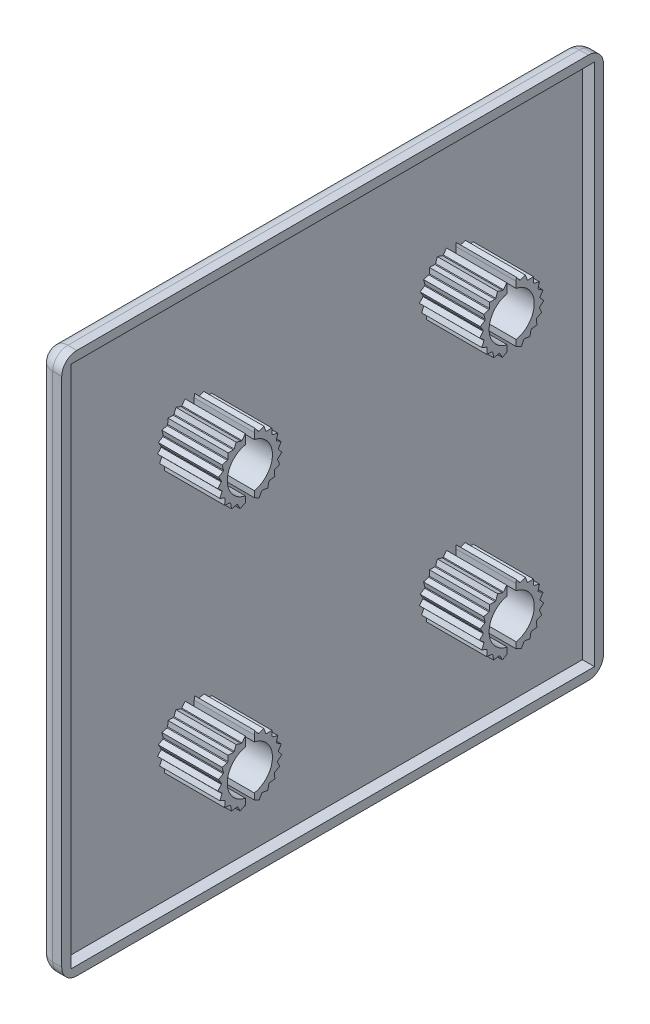
from build123d import *

# Parameters (mm, degrees)
EXTRUDE_3_DEPTH      = 45
EXTRUDE_3_DEPTH_BACK = 45
FILLET_3_R           = 2.5
SKETCH_6_W           = 87
SKETCH_6_H           = 87
CUT_EXTRUDE_2_DEPTH  = 2
EXTRUDE_5_DEPTH      = 10


with BuildPart() as part:
    # Sketch 3 → Extrude 3 (new body, two sides)
    with BuildSketch(Plane.XY) as extrude_3_sk:
        with BuildLine():
            Line((0.5, -45), (2, -45))
            Line((2, -45), (2, 45))
            Line((2, 45), (0.5, 45))
            ThreePointArc((0.5, 45), (-1.267766953, 44.267766953), (-2, 42.5))
            Line((-2, 42.5), (-2, -42.5))
            ThreePointArc((-2, -42.5), (-1.267766953, -44.267766953), (0.5, -45))
        make_face()
    extrude(amount=EXTRUDE_3_DEPTH)
    extrude(extrude_3_sk.sketch, amount=-EXTRUDE_3_DEPTH_BACK)

    # Fillet 3
    fillet_3_edges = [part.edges().sort_by_distance(p)[0] for p in [
        (-1.267766953, 44.267766953, -45),
        (-2, 0, -45),
        (1.25, 45, 45),
        (-1.267766953, 44.267766953, 45),
        (-2, 0, 45),
        (-1.267766953, -44.267766953, 45),
        (1.25, -45, 45),
        (-1.267766953, -44.267766953, -45),
        (1.25, -45, -45),
        (1.25, 45, -45),
    ]]
    fillet(fillet_3_edges, radius=FILLET_3_R)

    # Sketch 6 → Cut-Extrude 2 (cut)
    with BuildSketch(Plane(origin=(2, 0, 0), x_dir=(0, 0, -1), z_dir=(1, 0, 0))):
        Rectangle(SKETCH_6_W, SKETCH_6_H)
    extrude(amount=-CUT_EXTRUDE_2_DEPTH, mode=Mode.SUBTRACT)

    # Sketch 7 → Extrude 5 (add)
    with BuildSketch(Plane(origin=(0, 0, 0), x_dir=(0, 0, -1), z_dir=(1, 0, 0))):
        with BuildLine():
            Line((22.5, 17.05958424), (22.5, 18.075765386))
            ThreePointArc((22.5, 18.075765386), (25.5, 21.75), (22.5, 25.424234614))
            Line((22.5, 25.424234614), (22.5, 26.44041576))
            Line((22.5, 26.44041576), (22.513331825, 27.038769295))
            Line((22.513331825, 27.038769295), (23.052291729, 26.317990395))
            ThreePointArc((23.052291729, 26.317990395), (23.121651335, 26.297644733), (23.190693314, 26.276245991))
            Line((23.190693314, 26.276245991), (24.03831125, 26.578808109))
            Line((24.03831125, 26.578808109), (24.340873367, 25.731190173))
            ThreePointArc((24.340873367, 25.731190173), (24.401154531, 25.691304308), (24.460821779, 25.650505773))
            Line((24.460821779, 25.650505773), (25.359964178, 25.689786132))
            Line((25.359964178, 25.689786132), (25.399244537, 24.790643733))
            ThreePointArc((25.399244537, 24.790643733), (25.445091013, 24.7347617), (25.490081833, 24.678188499))
            Line((25.490081833, 24.678188499), (26.360855946, 24.450696867))
            Line((26.360855946, 24.450696867), (26.133364315, 23.579922753))
            ThreePointArc((26.133364315, 23.579922753), (26.160702442, 23.513009917), (26.187019202, 23.445688827))
            Line((26.187019202, 23.445688827), (26.95205293, 22.971638834))
            Line((26.95205293, 22.971638834), (26.478002937, 22.206605107))
            ThreePointArc((26.478002937, 22.206605107), (26.484403604, 22.134606965), (26.489707944, 22.062519761))
            Line((26.489707944, 22.062519761), (27.081024682, 21.38403283))
            Line((27.081024682, 21.38403283), (26.402537751, 20.792716093))
            ThreePointArc((26.402537751, 20.792716093), (26.387432228, 20.722029997), (26.371252836, 20.651581943))
            Line((26.371252836, 20.651581943), (26.736311496, 19.828944615))
            Line((26.736311496, 19.828944615), (25.913674167, 19.463885955))
            ThreePointArc((25.913674167, 19.463885955), (25.878404648, 19.400792674), (25.842179133, 19.33824339))
            Line((25.842179133, 19.33824339), (25.948542652, 18.444550601))
            Line((25.948542652, 18.444550601), (25.054849862, 18.338187082))
            ThreePointArc((25.054849862, 18.338187082), (25.002550198, 18.288292732), (24.949497356, 18.239199995))
            Line((24.949497356, 18.239199995), (24.787714868, 17.353860272))
            Line((24.787714868, 17.353860272), (23.902375144, 17.515642759))
            ThreePointArc((23.902375144, 17.515642759), (23.83769239, 17.483380672), (23.772526197, 17.452106588))
            Line((23.772526197, 17.452106588), (23.356972787, 16.653786249))
            Line((23.356972787, 16.653786249), (22.558652448, 17.06933966))
            ThreePointArc((22.558652448, 17.06933966), (22.529341488, 17.064370176), (22.5, 17.05958424))
        make_face()
        with BuildLine():
            Line((21, 17.05958424), (21, 18.075765386))
            ThreePointArc((21, 18.075765386), (18, 21.75), (21, 25.424234614))
            Line((21, 25.424234614), (21, 26.44041576))
            Line((21, 26.44041576), (20.920527018, 27.028800119))
            Line((20.920527018, 27.028800119), (20.390631523, 26.301331381))
            ThreePointArc((20.390631523, 26.301331381), (20.321532023, 26.28011912), (20.252763307, 26.257857838))
            Line((20.252763307, 26.257857838), (19.401424525, 26.549786388))
            Line((19.401424525, 26.549786388), (19.109495975, 25.698447606))
            ThreePointArc((19.109495975, 25.698447606), (19.049718796, 25.65781031), (18.990566909, 25.6162681))
            Line((18.990566909, 25.6162681), (18.09100327, 25.644290572))
            Line((18.09100327, 25.644290572), (18.062980798, 24.744726933))
            ThreePointArc((18.062980798, 24.744726933), (18.017837404, 24.688275405), (17.973558251, 24.631143474))
            Line((17.973558251, 24.631143474), (17.105699932, 24.392769949))
            Line((17.105699932, 24.392769949), (17.344073456, 23.52491163))
            ThreePointArc((17.344073456, 23.52491163), (17.317575037, 23.457661836), (17.292103015, 23.390016607))
            Line((17.292103015, 23.390016607), (16.533063036, 22.906427619))
            Line((16.533063036, 22.906427619), (17.016652024, 22.147387639))
            ThreePointArc((17.016652024, 22.147387639), (17.011153079, 22.075315019), (17.006751489, 22.003167067))
            Line((17.006751489, 22.003167067), (16.423973883, 21.317331619))
            Line((16.423973883, 21.317331619), (17.109809331, 20.734554013))
            ThreePointArc((17.109809331, 20.734554013), (17.125798467, 20.664062535), (17.142858409, 20.593822523))
            Line((17.142858409, 20.593822523), (16.788125523, 19.766680104))
            Line((16.788125523, 19.766680104), (17.615267942, 19.411947219))
            ThreePointArc((17.615267942, 19.411947219), (17.651324453, 19.34930036), (17.688330077, 19.287209421))
            Line((17.688330077, 19.287209421), (17.593161486, 18.392255266))
            Line((17.593161486, 18.392255266), (18.488115641, 18.297086675))
            ThreePointArc((18.488115641, 18.297086675), (18.541035749, 18.247850884), (18.594698942, 18.19942607))
            Line((18.594698942, 18.19942607), (18.767550793, 17.316180782))
            Line((18.767550793, 17.316180782), (19.65079608, 17.489032633))
            ThreePointArc((19.65079608, 17.489032633), (19.7158776, 17.457582725), (19.781430153, 17.427126794))
            Line((19.781430153, 17.427126794), (20.2069438, 16.634070594))
            Line((20.2069438, 16.634070594), (21, 17.05958424))
        make_face()
        with BuildLine():
            Line((-22.5, 26.44041576), (-22.513331825, 27.038769295))
            Line((-22.513331825, 27.038769295), (-23.052291729, 26.317990395))
            ThreePointArc((-23.052291729, 26.317990395), (-23.121651335, 26.297644733), (-23.190693314, 26.276245991))
            Line((-23.190693314, 26.276245991), (-24.03831125, 26.578808109))
            Line((-24.03831125, 26.578808109), (-24.340873367, 25.731190173))
            ThreePointArc((-24.340873367, 25.731190173), (-24.401154531, 25.691304308), (-24.460821779, 25.650505773))
            Line((-24.460821779, 25.650505773), (-25.359964178, 25.689786132))
            Line((-25.359964178, 25.689786132), (-25.399244537, 24.790643733))
            ThreePointArc((-25.399244537, 24.790643733), (-25.445091013, 24.7347617), (-25.490081833, 24.678188499))
            Line((-25.490081833, 24.678188499), (-26.360855946, 24.450696867))
            Line((-26.360855946, 24.450696867), (-26.133364315, 23.579922753))
            ThreePointArc((-26.133364315, 23.579922753), (-26.160702442, 23.513009917), (-26.187019202, 23.445688827))
            Line((-26.187019202, 23.445688827), (-26.95205293, 22.971638834))
            Line((-26.95205293, 22.971638834), (-26.478002937, 22.206605107))
            ThreePointArc((-26.478002937, 22.206605107), (-26.484403604, 22.134606965), (-26.489707944, 22.062519761))
            Line((-26.489707944, 22.062519761), (-27.081024682, 21.38403283))
            Line((-27.081024682, 21.38403283), (-26.402537751, 20.792716093))
            ThreePointArc((-26.402537751, 20.792716093), (-26.387432228, 20.722029997), (-26.371252836, 20.651581943))
            Line((-26.371252836, 20.651581943), (-26.736311496, 19.828944615))
            Line((-26.736311496, 19.828944615), (-25.913674167, 19.463885955))
            ThreePointArc((-25.913674167, 19.463885955), (-25.878404648, 19.400792674), (-25.842179133, 19.33824339))
            Line((-25.842179133, 19.33824339), (-25.948542652, 18.444550601))
            Line((-25.948542652, 18.444550601), (-25.054849862, 18.338187082))
            ThreePointArc((-25.054849862, 18.338187082), (-25.002550198, 18.288292732), (-24.949497356, 18.239199995))
            Line((-24.949497356, 18.239199995), (-24.787714868, 17.353860272))
            Line((-24.787714868, 17.353860272), (-23.902375144, 17.515642759))
            ThreePointArc((-23.902375144, 17.515642759), (-23.83769239, 17.483380672), (-23.772526197, 17.452106588))
            Line((-23.772526197, 17.452106588), (-23.356972787, 16.653786249))
            Line((-23.356972787, 16.653786249), (-22.558652448, 17.06933966))
            ThreePointArc((-22.558652448, 17.06933966), (-22.529341488, 17.064370176), (-22.5, 17.05958424))
            Line((-22.5, 17.05958424), (-22.5, 18.075765386))
            ThreePointArc((-22.5, 18.075765386), (-25.5, 21.75), (-22.5, 25.424234614))
            Line((-22.5, 25.424234614), (-22.5, 26.44041576))
        make_face()
        with BuildLine():
            Line((-21, 26.44041576), (-20.920527018, 27.028800119))
            Line((-20.920527018, 27.028800119), (-20.390631523, 26.301331381))
            ThreePointArc((-20.390631523, 26.301331381), (-20.321532023, 26.28011912), (-20.252763307, 26.257857838))
            Line((-20.252763307, 26.257857838), (-19.401424525, 26.549786388))
            Line((-19.401424525, 26.549786388), (-19.109495975, 25.698447606))
            ThreePointArc((-19.109495975, 25.698447606), (-19.049718796, 25.65781031), (-18.990566909, 25.6162681))
            Line((-18.990566909, 25.6162681), (-18.09100327, 25.644290572))
            Line((-18.09100327, 25.644290572), (-18.062980798, 24.744726933))
            ThreePointArc((-18.062980798, 24.744726933), (-18.017837404, 24.688275405), (-17.973558251, 24.631143474))
            Line((-17.973558251, 24.631143474), (-17.105699932, 24.392769949))
            Line((-17.105699932, 24.392769949), (-17.344073456, 23.52491163))
            ThreePointArc((-17.344073456, 23.52491163), (-17.317575037, 23.457661836), (-17.292103015, 23.390016607))
            Line((-17.292103015, 23.390016607), (-16.533063036, 22.906427619))
            Line((-16.533063036, 22.906427619), (-17.016652024, 22.147387639))
            ThreePointArc((-17.016652024, 22.147387639), (-17.011153079, 22.075315019), (-17.006751489, 22.003167067))
            Line((-17.006751489, 22.003167067), (-16.423973883, 21.317331619))
            Line((-16.423973883, 21.317331619), (-17.109809331, 20.734554013))
            ThreePointArc((-17.109809331, 20.734554013), (-17.125798467, 20.664062535), (-17.142858409, 20.593822523))
            Line((-17.142858409, 20.593822523), (-16.788125523, 19.766680104))
            Line((-16.788125523, 19.766680104), (-17.615267942, 19.411947219))
            ThreePointArc((-17.615267942, 19.411947219), (-17.651324453, 19.34930036), (-17.688330077, 19.287209421))
            Line((-17.688330077, 19.287209421), (-17.593161486, 18.392255266))
            Line((-17.593161486, 18.392255266), (-18.488115641, 18.297086675))
            ThreePointArc((-18.488115641, 18.297086675), (-18.541035749, 18.247850884), (-18.594698942, 18.19942607))
            Line((-18.594698942, 18.19942607), (-18.767550793, 17.316180782))
            Line((-18.767550793, 17.316180782), (-19.65079608, 17.489032633))
            ThreePointArc((-19.65079608, 17.489032633), (-19.7158776, 17.457582725), (-19.781430153, 17.427126794))
            Line((-19.781430153, 17.427126794), (-20.2069438, 16.634070594))
            Line((-20.2069438, 16.634070594), (-21, 17.05958424))
            Line((-21, 17.05958424), (-21, 18.075765386))
            ThreePointArc((-21, 18.075765386), (-18, 21.75), (-21, 25.424234614))
            Line((-21, 25.424234614), (-21, 26.44041576))
        make_face()
        with BuildLine():
            Line((22.5, -26.44041576), (22.5, -25.424234614))
            ThreePointArc((22.5, -25.424234614), (25.5, -21.75), (22.5, -18.075765386))
            Line((22.5, -18.075765386), (22.5, -17.05958424))
            Line((22.5, -17.05958424), (22.513331825, -16.461230705))
            Line((22.513331825, -16.461230705), (23.052291729, -17.182009605))
            ThreePointArc((23.052291729, -17.182009605), (23.121651335, -17.202355267), (23.190693314, -17.223754009))
            Line((23.190693314, -17.223754009), (24.03831125, -16.921191891))
            Line((24.03831125, -16.921191891), (24.340873367, -17.768809827))
            ThreePointArc((24.340873367, -17.768809827), (24.401154531, -17.808695692), (24.460821779, -17.849494227))
            Line((24.460821779, -17.849494227), (25.359964178, -17.810213868))
            Line((25.359964178, -17.810213868), (25.399244537, -18.709356267))
            ThreePointArc((25.399244537, -18.709356267), (25.445091013, -18.7652383), (25.490081833, -18.821811501))
            Line((25.490081833, -18.821811501), (26.360855946, -19.049303133))
            Line((26.360855946, -19.049303133), (26.133364315, -19.920077247))
            ThreePointArc((26.133364315, -19.920077247), (26.160702442, -19.986990083), (26.187019202, -20.054311173))
            Line((26.187019202, -20.054311173), (26.95205293, -20.528361166))
            Line((26.95205293, -20.528361166), (26.478002937, -21.293394893))
            ThreePointArc((26.478002937, -21.293394893), (26.484403604, -21.365393035), (26.489707944, -21.437480239))
            Line((26.489707944, -21.437480239), (27.081024682, -22.11596717))
            Line((27.081024682, -22.11596717), (26.402537751, -22.707283907))
            ThreePointArc((26.402537751, -22.707283907), (26.387432228, -22.777970003), (26.371252836, -22.848418057))
            Line((26.371252836, -22.848418057), (26.736311496, -23.671055385))
            Line((26.736311496, -23.671055385), (25.913674167, -24.036114045))
            ThreePointArc((25.913674167, -24.036114045), (25.878404648, -24.099207326), (25.842179133, -24.16175661))
            Line((25.842179133, -24.16175661), (25.948542652, -25.055449399))
            Line((25.948542652, -25.055449399), (25.054849862, -25.161812918))
            ThreePointArc((25.054849862, -25.161812918), (25.002550198, -25.211707268), (24.949497356, -25.260800005))
            Line((24.949497356, -25.260800005), (24.787714868, -26.146139728))
            Line((24.787714868, -26.146139728), (23.902375144, -25.984357241))
            ThreePointArc((23.902375144, -25.984357241), (23.83769239, -26.016619328), (23.772526197, -26.047893412))
            Line((23.772526197, -26.047893412), (23.356972787, -26.846213751))
            Line((23.356972787, -26.846213751), (22.558652448, -26.43066034))
            ThreePointArc((22.558652448, -26.43066034), (22.529341488, -26.435629824), (22.5, -26.44041576))
        make_face()
        with BuildLine():
            Line((21, -26.44041576), (21, -25.424234614))
            ThreePointArc((21, -25.424234614), (18, -21.75), (21, -18.075765386))
            Line((21, -18.075765386), (21, -17.05958424))
            Line((21, -17.05958424), (20.920527018, -16.471199881))
            Line((20.920527018, -16.471199881), (20.390631523, -17.198668619))
            ThreePointArc((20.390631523, -17.198668619), (20.321532023, -17.21988088), (20.252763307, -17.242142162))
            Line((20.252763307, -17.242142162), (19.401424525, -16.950213612))
            Line((19.401424525, -16.950213612), (19.109495975, -17.801552394))
            ThreePointArc((19.109495975, -17.801552394), (19.049718796, -17.84218969), (18.990566909, -17.8837319))
            Line((18.990566909, -17.8837319), (18.09100327, -17.855709428))
            Line((18.09100327, -17.855709428), (18.062980798, -18.755273067))
            ThreePointArc((18.062980798, -18.755273067), (18.017837404, -18.811724595), (17.973558251, -18.868856526))
            Line((17.973558251, -18.868856526), (17.105699932, -19.107230051))
            Line((17.105699932, -19.107230051), (17.344073456, -19.97508837))
            ThreePointArc((17.344073456, -19.97508837), (17.317575037, -20.042338164), (17.292103015, -20.109983393))
            Line((17.292103015, -20.109983393), (16.533063036, -20.593572381))
            Line((16.533063036, -20.593572381), (17.016652024, -21.352612361))
            ThreePointArc((17.016652024, -21.352612361), (17.011153079, -21.424684981), (17.006751489, -21.496832933))
            Line((17.006751489, -21.496832933), (16.423973883, -22.182668381))
            Line((16.423973883, -22.182668381), (17.109809331, -22.765445987))
            ThreePointArc((17.109809331, -22.765445987), (17.125798467, -22.835937465), (17.142858409, -22.906177477))
            Line((17.142858409, -22.906177477), (16.788125523, -23.733319896))
            Line((16.788125523, -23.733319896), (17.615267942, -24.088052781))
            ThreePointArc((17.615267942, -24.088052781), (17.651324453, -24.15069964), (17.688330077, -24.212790579))
            Line((17.688330077, -24.212790579), (17.593161486, -25.107744734))
            Line((17.593161486, -25.107744734), (18.488115641, -25.202913325))
            ThreePointArc((18.488115641, -25.202913325), (18.541035749, -25.252149116), (18.594698942, -25.30057393))
            Line((18.594698942, -25.30057393), (18.767550793, -26.183819218))
            Line((18.767550793, -26.183819218), (19.65079608, -26.010967367))
            ThreePointArc((19.65079608, -26.010967367), (19.7158776, -26.042417275), (19.781430153, -26.072873206))
            Line((19.781430153, -26.072873206), (20.2069438, -26.865929406))
            Line((20.2069438, -26.865929406), (21, -26.44041576))
        make_face()
        with BuildLine():
            Line((-22.5, -17.05958424), (-22.513331825, -16.461230705))
            Line((-22.513331825, -16.461230705), (-23.052291729, -17.182009605))
            ThreePointArc((-23.052291729, -17.182009605), (-23.121651335, -17.202355267), (-23.190693314, -17.223754009))
            Line((-23.190693314, -17.223754009), (-24.03831125, -16.921191891))
            Line((-24.03831125, -16.921191891), (-24.340873367, -17.768809827))
            ThreePointArc((-24.340873367, -17.768809827), (-24.401154531, -17.808695692), (-24.460821779, -17.849494227))
            Line((-24.460821779, -17.849494227), (-25.359964178, -17.810213868))
            Line((-25.359964178, -17.810213868), (-25.399244537, -18.709356267))
            ThreePointArc((-25.399244537, -18.709356267), (-25.445091013, -18.7652383), (-25.490081833, -18.821811501))
            Line((-25.490081833, -18.821811501), (-26.360855946, -19.049303133))
            Line((-26.360855946, -19.049303133), (-26.133364315, -19.920077247))
            ThreePointArc((-26.133364315, -19.920077247), (-26.160702442, -19.986990083), (-26.187019202, -20.054311173))
            Line((-26.187019202, -20.054311173), (-26.95205293, -20.528361166))
            Line((-26.95205293, -20.528361166), (-26.478002937, -21.293394893))
            ThreePointArc((-26.478002937, -21.293394893), (-26.484403604, -21.365393035), (-26.489707944, -21.437480239))
            Line((-26.489707944, -21.437480239), (-27.081024682, -22.11596717))
            Line((-27.081024682, -22.11596717), (-26.402537751, -22.707283907))
            ThreePointArc((-26.402537751, -22.707283907), (-26.387432228, -22.777970003), (-26.371252836, -22.848418057))
            Line((-26.371252836, -22.848418057), (-26.736311496, -23.671055385))
            Line((-26.736311496, -23.671055385), (-25.913674167, -24.036114045))
            ThreePointArc((-25.913674167, -24.036114045), (-25.878404648, -24.099207326), (-25.842179133, -24.16175661))
            Line((-25.842179133, -24.16175661), (-25.948542652, -25.055449399))
            Line((-25.948542652, -25.055449399), (-25.054849862, -25.161812918))
            ThreePointArc((-25.054849862, -25.161812918), (-25.002550198, -25.211707268), (-24.949497356, -25.260800005))
            Line((-24.949497356, -25.260800005), (-24.787714868, -26.146139728))
            Line((-24.787714868, -26.146139728), (-23.902375144, -25.984357241))
            ThreePointArc((-23.902375144, -25.984357241), (-23.83769239, -26.016619328), (-23.772526197, -26.047893412))
            Line((-23.772526197, -26.047893412), (-23.356972787, -26.846213751))
            Line((-23.356972787, -26.846213751), (-22.558652448, -26.43066034))
            ThreePointArc((-22.558652448, -26.43066034), (-22.529341488, -26.435629824), (-22.5, -26.44041576))
            Line((-22.5, -26.44041576), (-22.5, -25.424234614))
            ThreePointArc((-22.5, -25.424234614), (-25.5, -21.75), (-22.5, -18.075765386))
            Line((-22.5, -18.075765386), (-22.5, -17.05958424))
        make_face()
        with BuildLine():
            Line((-21, -17.05958424), (-20.920527018, -16.471199881))
            Line((-20.920527018, -16.471199881), (-20.390631523, -17.198668619))
            ThreePointArc((-20.390631523, -17.198668619), (-20.321532023, -17.21988088), (-20.252763307, -17.242142162))
            Line((-20.252763307, -17.242142162), (-19.401424525, -16.950213612))
            Line((-19.401424525, -16.950213612), (-19.109495975, -17.801552394))
            ThreePointArc((-19.109495975, -17.801552394), (-19.049718796, -17.84218969), (-18.990566909, -17.8837319))
            Line((-18.990566909, -17.8837319), (-18.09100327, -17.855709428))
            Line((-18.09100327, -17.855709428), (-18.062980798, -18.755273067))
            ThreePointArc((-18.062980798, -18.755273067), (-18.017837404, -18.811724595), (-17.973558251, -18.868856526))
            Line((-17.973558251, -18.868856526), (-17.105699932, -19.107230051))
            Line((-17.105699932, -19.107230051), (-17.344073456, -19.97508837))
            ThreePointArc((-17.344073456, -19.97508837), (-17.317575037, -20.042338164), (-17.292103015, -20.109983393))
            Line((-17.292103015, -20.109983393), (-16.533063036, -20.593572381))
            Line((-16.533063036, -20.593572381), (-17.016652024, -21.352612361))
            ThreePointArc((-17.016652024, -21.352612361), (-17.011153079, -21.424684981), (-17.006751489, -21.496832933))
            Line((-17.006751489, -21.496832933), (-16.423973883, -22.182668381))
            Line((-16.423973883, -22.182668381), (-17.109809331, -22.765445987))
            ThreePointArc((-17.109809331, -22.765445987), (-17.125798467, -22.835937465), (-17.142858409, -22.906177477))
            Line((-17.142858409, -22.906177477), (-16.788125523, -23.733319896))
            Line((-16.788125523, -23.733319896), (-17.615267942, -24.088052781))
            ThreePointArc((-17.615267942, -24.088052781), (-17.651324453, -24.15069964), (-17.688330077, -24.212790579))
            Line((-17.688330077, -24.212790579), (-17.593161486, -25.107744734))
            Line((-17.593161486, -25.107744734), (-18.488115641, -25.202913325))
            ThreePointArc((-18.488115641, -25.202913325), (-18.541035749, -25.252149116), (-18.594698942, -25.30057393))
            Line((-18.594698942, -25.30057393), (-18.767550793, -26.183819218))
            Line((-18.767550793, -26.183819218), (-19.65079608, -26.010967367))
            ThreePointArc((-19.65079608, -26.010967367), (-19.7158776, -26.042417275), (-19.781430153, -26.072873206))
            Line((-19.781430153, -26.072873206), (-20.2069438, -26.865929406))
            Line((-20.2069438, -26.865929406), (-21, -26.44041576))
            Line((-21, -26.44041576), (-21, -25.424234614))
            ThreePointArc((-21, -25.424234614), (-18, -21.75), (-21, -18.075765386))
            Line((-21, -18.075765386), (-21, -17.05958424))
        make_face()
    extrude(amount=EXTRUDE_5_DEPTH)


solid = part.part
